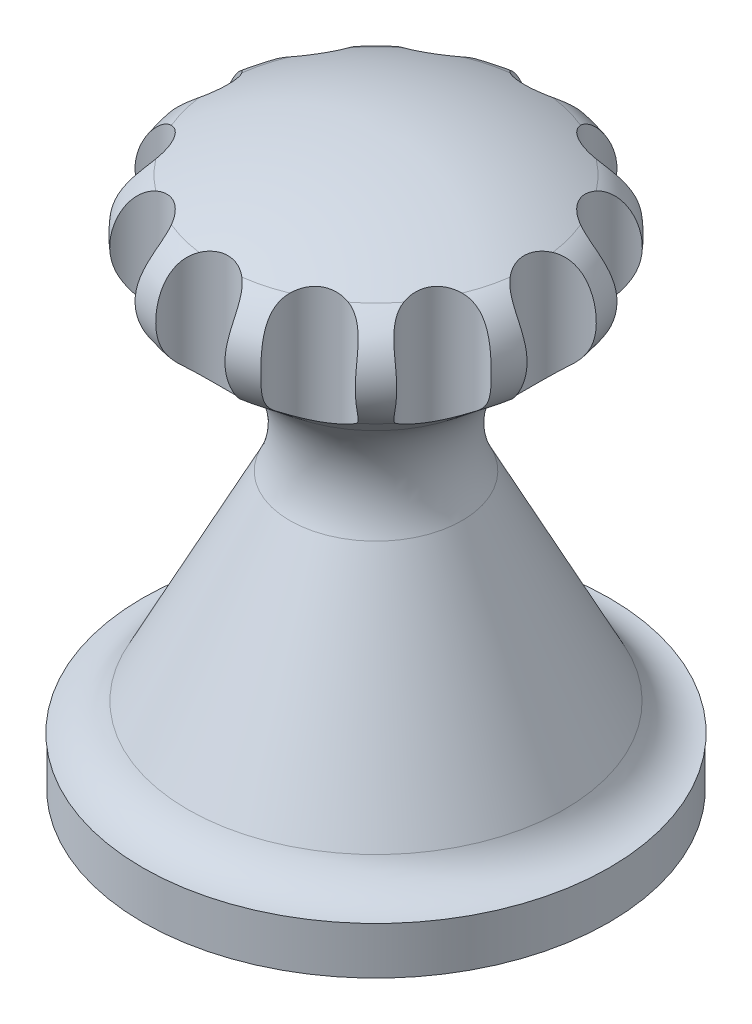
from build123d import *

# Parameters (mm, degrees)
SKIZZE2_W          = 37.72049671
SKIZZE2_H          = 150
KREISMUSTER1_COUNT = 12


with BuildPart() as part:
    # Skizze1 → Rotation1 (revolve)
    with BuildSketch(Plane.XY, mode=Mode.PRIVATE) as rotation1_sk:
        with BuildLine():
            Line((0, 0), (-253.117185477, 0))
            Line((-253.117185477, 0), (-253.117185477, 51.792955444))
            Line((-253.117185477, 51.792955444), (-253.647448846, 51.792955444))
            ThreePointArc((-253.647448846, 51.792955444), (-224.820028844, 59.906916663), (-204.45725205, 81.866284412))
            Line((-204.45725205, 81.866284412), (-93.604758831, 298.310210038))
            ThreePointArc((-93.604758831, 298.310210038), (-84.839161715, 363.917866265), (-119.333786425, 420.409645443))
            Line((-119.333786425, 420.409645443), (-181.808838535, 471.148820492))
            ThreePointArc((-181.808838535, 471.148820492), (-204.835844041, 526.982993694), (-170.540242818, 576.697273497))
            ThreePointArc((-170.540242818, 576.697273497), (-87.673640788, 607.13771538), (0, 617.473427503))
            Line((0, 617.473427503), (0, 0))
        make_face()
    revolve(rotation1_sk.sketch.rotate(Axis((0, 617.473427503, 0), (0, -1, 0)), 270), axis=Axis((0, 617.473427503, 0), (0, -1, 0)))  # turned: the seam where the file's is

    # Skizze2 → Schnitt-Rotation1 (revolve, cut)
    with BuildSketch(Plane.XY):
        with Locations((-217.529470426, 520.265787447)):
            Rectangle(SKIZZE2_W, SKIZZE2_H)
    schnitt_rotation1 = revolve(axis=Axis((-198.669222071, 595.265787447, 0), (0, -1, 0)), mode=Mode.SUBTRACT)

    # Kreismuster1: Schnitt-Rotation1 ×12 about axis
    kreismuster1_axis = Axis((0, 0, 0), (0, 1, 0))
    for i in range(1, KREISMUSTER1_COUNT):
        add(schnitt_rotation1.rotate(kreismuster1_axis, i * 360 / KREISMUSTER1_COUNT), mode=Mode.SUBTRACT)


solid = part.part
